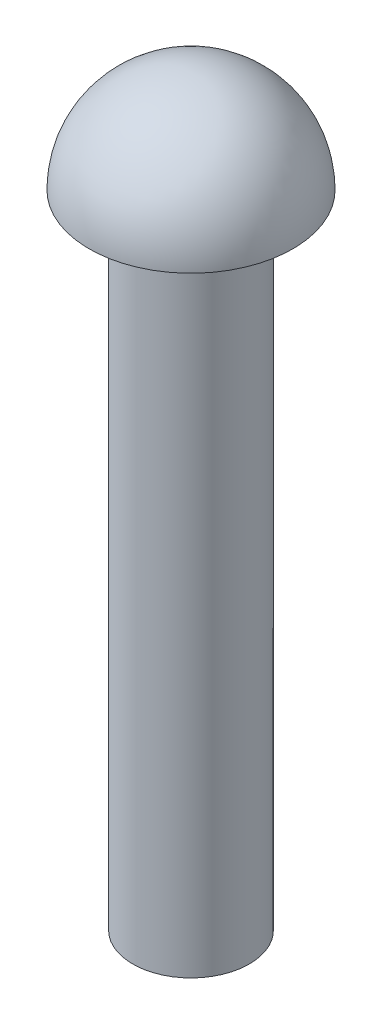
from build123d import *


with BuildPart() as part:
    # Sketch1 → Revolve-Thin1 (revolve)
    with BuildSketch(Plane.XY):
        with BuildLine():
            Line((0, 0), (3.175, 0))
            Line((3.175, 0), (3.175, 34.925))
            Line((3.175, 34.925), (5.5499, 34.925))
            ThreePointArc((5.5499, 34.925), (3.924371925, 38.849371925), (0, 40.4749))
            Line((0, 40.4749), (0, 37.9349))
            ThreePointArc((0, 37.9349), (0.840937575, 37.815038409), (1.614898762, 37.465))
            Line((1.614898762, 37.465), (0.635, 37.465))
            Line((0.635, 37.465), (0.635, 2.54))
            Line((0.635, 2.54), (0, 2.54))
            Line((0, 2.54), (0, 0))
        make_face()
    revolve(axis=Axis((0, 0, 0), (0, 1, 0)))


solid = part.part
